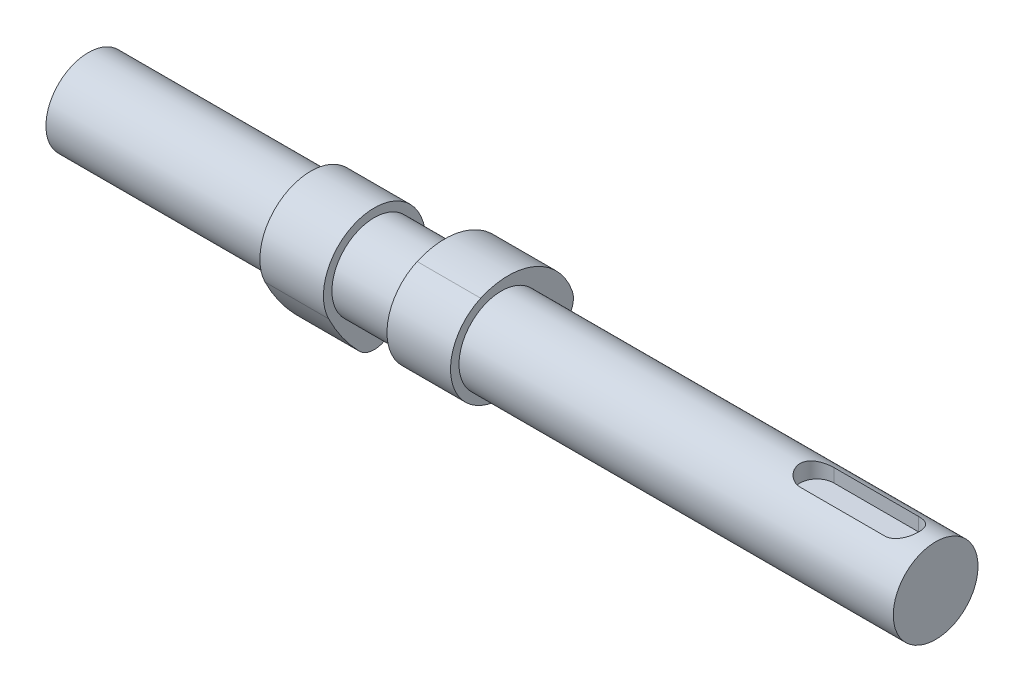
from build123d import *

# Parameters (mm, degrees)
SKETCH1_R                = 10
BOSS_EXTRUDE1_DEPTH      = 125
BOSS_EXTRUDE1_DEPTH_BACK = 75
BOSS_EXTRUDE2_START      = 15
BOSS_EXTRUDE2_DEPTH      = 7.5
BODY_MOVE_COPY2_ANGLE    = 90
CUT_EXTRUDE1_DEPTH       = 4


with BuildPart() as part:
    # Sketch1 → Boss-Extrude1 (new body, two sides)
    with BuildSketch(Plane(origin=(0, 0, 0), x_dir=(0, 0, -1), z_dir=(1, 0, 0))) as boss_extrude1_sk:
        Circle(SKETCH1_R)
    extrude(amount=BOSS_EXTRUDE1_DEPTH)
    extrude(boss_extrude1_sk.sketch, amount=-BOSS_EXTRUDE1_DEPTH_BACK)

    # Sketch3 → Cut-Extrude1 (cut)
    with BuildSketch(Plane(origin=(0, 10, 0), x_dir=(1, 0, 0), z_dir=(0, 1, 0))):
        with BuildLine():
            Line((117, -4), (97, -4))
            ThreePointArc((97, -4), (93, 0), (97, 4))
            Line((97, 4), (117, 4))
            ThreePointArc((117, 4), (121, 0), (117, -4))
        make_face()
    extrude(amount=-CUT_EXTRUDE1_DEPTH, mode=Mode.SUBTRACT)


with BuildPart() as body_2:
    # Sketch2 → Boss-Extrude2 (new body, symmetric)
    with BuildSketch(Plane(origin=(0, 0, 0), x_dir=(0, 0, -1), z_dir=(1, 0, 0)).offset(BOSS_EXTRUDE2_START)):
        with BuildLine():
            ThreePointArc((-4.875, 10.965143638), (-10.866880674, -5.090275475), (5.303571429, -10.764391766))
            ThreePointArc((5.303571429, -10.764391766), (10.673861143, -7.574827955), (15.482142857, -3.588130589))
            ThreePointArc((15.482142857, -3.588130589), (16.867377987, -1.143954342), (16.715909091, 1.6613854))
            ThreePointArc((16.715909091, 1.6613854), (7.956738236, 11.038797462), (-4.875, 10.965143638))
        make_face()
    extrude(amount=BOSS_EXTRUDE2_DEPTH, both=True)


with BuildPart() as body_3:
    # Mirror3: mirrored copy
    add(body_2.part.mirror(Plane(origin=(0, 0, 0), x_dir=(0, 0, 1), z_dir=(1, 0, 0))))


with BuildPart() as body_3_1:
    # Body-Move/Copy2: moved
    add(body_3.part.rotate(Axis((0, 0, 0), (-1, 0, 0)), BODY_MOVE_COPY2_ANGLE))


solid = Compound([part.part, body_2.part, body_3_1.part])
